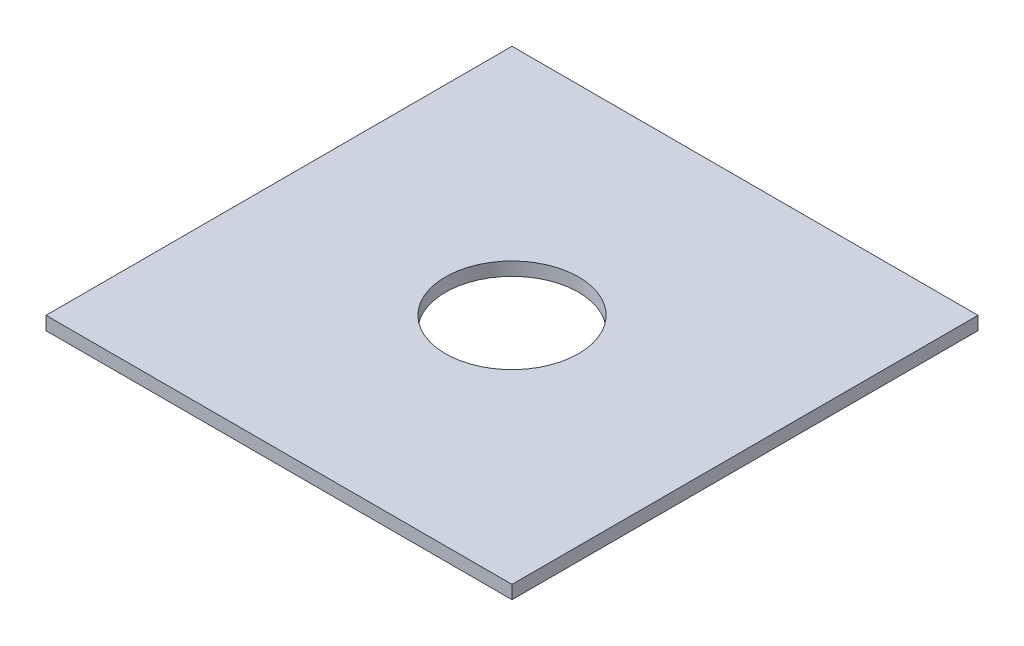
from build123d import *

# Parameters (mm, degrees)
ESQUISSE1_W      = 350
ESQUISSE1_H      = 350
EXTRUSION1_DEPTH = 10
ESQUISSE2_R      = 50
EXTRUSION2_DEPTH = 10


with BuildPart() as part:
    # Esquisse1 → Extrusion1 (new body)
    with BuildSketch(Plane(origin=(0, 0, 0), x_dir=(1, 0, 0), z_dir=(0, 1, 0))):
        with Locations((175, 175)):
            Rectangle(ESQUISSE1_W, ESQUISSE1_H)
    extrude(amount=EXTRUSION1_DEPTH)

    # Esquisse2 → Extrusion2 (cut)
    with BuildSketch(Plane(origin=(0, 10, 0), x_dir=(1, 0, 0), z_dir=(0, 1, 0))):
        with Locations((175, 175)):
            Circle(ESQUISSE2_R)
    extrude(amount=-EXTRUSION2_DEPTH, mode=Mode.SUBTRACT)


solid = part.part
